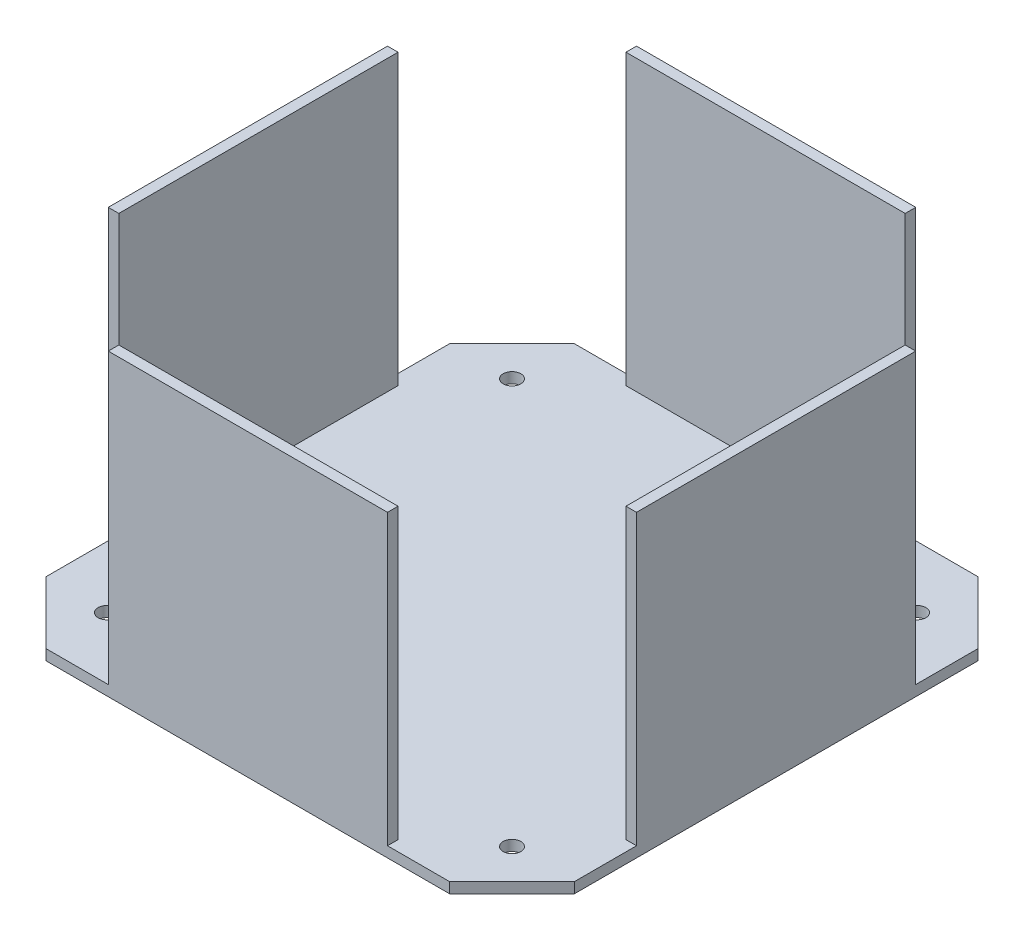
from build123d import *

# Parameters (mm, degrees)
SKETCH2_W           = 150
SKETCH2_H           = 150
BOSS_EXTRUDE1_DEPTH = 85
SHELL1_T            = -3
CUT_EXTRUDE1_DEPTH  = 82
CUT_EXTRUDE2_DEPTH  = 4
SKETCH5_R           = 2.5
CUT_EXTRUDE3_DEPTH  = 4


with BuildPart() as part:
    # Sketch2 → Boss-Extrude1 (new body)
    with BuildSketch(Plane(origin=(0, 0, 0), x_dir=(1, 0, 0), z_dir=(0, 1, 0))):
        Rectangle(SKETCH2_W, SKETCH2_H)
    extrude(amount=BOSS_EXTRUDE1_DEPTH)

    # Shell1
    shell1_openings = [part.faces().sort_by_distance(p)[0] for p in [
        (0, 85, 0),
    ]]
    offset(amount=SHELL1_T, openings=shell1_openings, kind=Kind.INTERSECTION)

    # Sketch3 → Cut-Extrude1 (cut)
    with BuildSketch(Plane(origin=(0, 85, 0), x_dir=(1, 0, 0), z_dir=(0, 1, 0))):
        Polygon((39.644660941, -75), (75, -75), (75, -39.644660941), (72, -39.644660941), (72, -42.644660941), (72, -72), (39.644660941, -72), align=None)
        Polygon((-39.644660941, -72), (-42.644660941, -72), (-72, -72), (-72, -39.644660941), (-75, -39.644660941), (-75, -75), (-39.644660941, -75), align=None)
        Polygon((-72, 39.644660941), (-72, 42.644660941), (-72, 72), (-39.644660941, 72), (-39.644660941, 75), (-75, 75), (-75, 39.644660941), align=None)
        Polygon((39.644660941, 72), (42.644660941, 72), (72, 72), (72, 39.644660941), (75, 39.644660941), (75, 75), (39.644660941, 75), align=None)
    extrude(amount=-CUT_EXTRUDE1_DEPTH, mode=Mode.SUBTRACT)

    # Sketch4 → Cut-Extrude2 (cut, through all)
    with BuildSketch(Plane(origin=(0, 3, 0), x_dir=(1, 0, 0), z_dir=(0, 1, 0))):
        Polygon((-75, -57.32233047), (-75, -75), (-57.32233047, -75), align=None)
        Polygon((-75, 57.32233047), (-57.32233047, 75), (-75, 75), align=None)
        Polygon((57.32233047, 75), (75, 57.32233047), (75, 75), align=None)
        Polygon((75, -57.32233047), (57.32233047, -75), (75, -75), align=None)
    extrude(amount=-CUT_EXTRUDE2_DEPTH, mode=Mode.SUBTRACT)

    # Sketch5 → Cut-Extrude3 (cut, through all)
    with BuildSketch(Plane(origin=(0, 3, 0), x_dir=(1, 0, 0), z_dir=(0, 1, 0))):
        with Locations((57.511546526, 57.511546526)):
            Circle(SKETCH5_R)
        with Locations((57.511546526, -57.511546526)):
            Circle(SKETCH5_R)
        with Locations((-57.511546526, -57.511546526)):
            Circle(SKETCH5_R)
        with Locations((-57.511546526, 57.511546526)):
            Circle(SKETCH5_R)
    extrude(amount=-CUT_EXTRUDE3_DEPTH, mode=Mode.SUBTRACT)


solid = part.part
